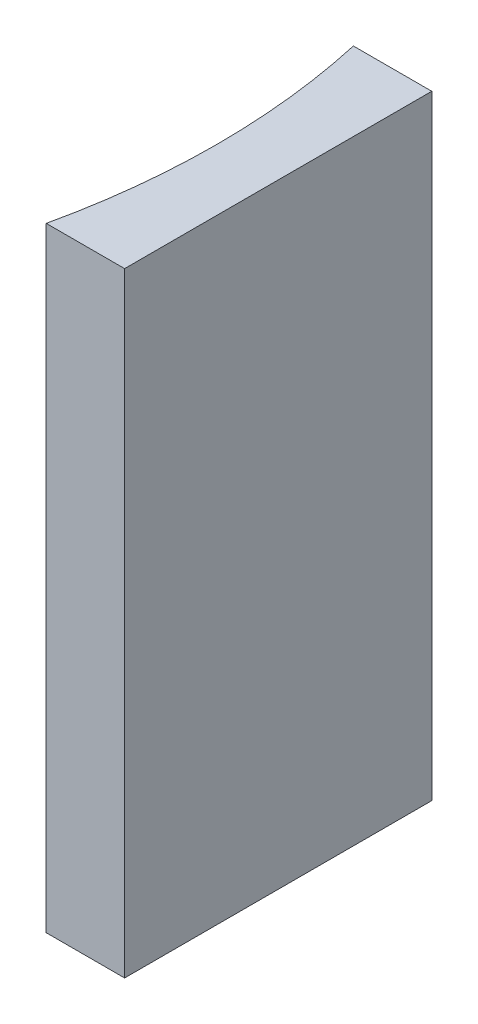
from build123d import *

# Parameters (mm, degrees)
EXTRUDE_1_DEPTH = 20


with BuildPart() as part:
    # 草图1 → 凸台-拉伸1 (new body)
    with BuildSketch(Plane(origin=(0, 0, 0), x_dir=(1, 0, 0), z_dir=(0, 1, 0))):
        with BuildLine():
            Line((0, 0), (0, -10))
            Line((0, -10), (-2.55202289, -10))
            ThreePointArc((-2.55202289, -10), (-2, -5), (-2.55202289, 0))
            Line((-2.55202289, 0), (0, 0))
        make_face()
    extrude(amount=EXTRUDE_1_DEPTH)


solid = part.part
